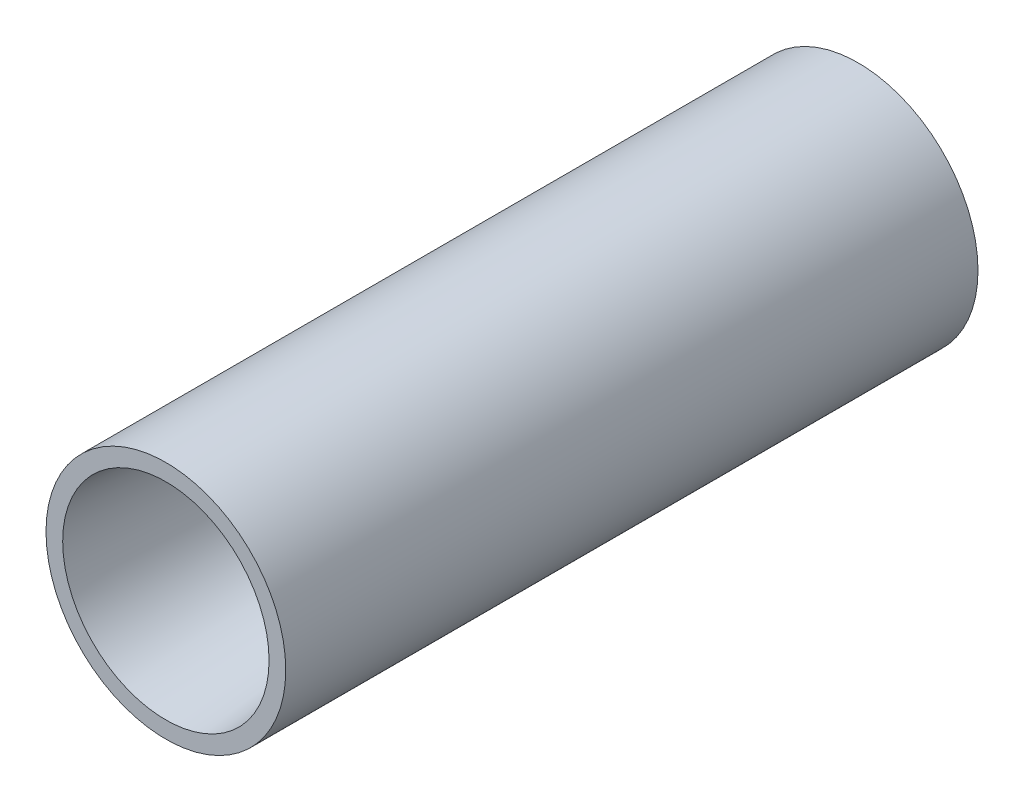
from build123d import *

# Parameters (mm, degrees)
SKETCH1_R           = 12.121929558
BOSS_EXTRUDE1_DEPTH = 70
SKETCH2_R           = 6.435362547
CUT_EXTRUDE1_DEPTH  = 60
CHAMFER1_SIZE       = 4
CHAMFER1_SIZE2      = 45.720209211


with BuildPart() as part:
    # Sketch1 → Boss-Extrude1 (new body)
    with BuildSketch(Plane.XY):
        Circle(SKETCH1_R)
    extrude(amount=BOSS_EXTRUDE1_DEPTH)

    # Sketch2 → Cut-Extrude1 (cut)
    with BuildSketch(Plane.XY.offset(70)):
        Circle(SKETCH2_R)
    extrude(amount=-CUT_EXTRUDE1_DEPTH, mode=Mode.SUBTRACT)

    # Chamfer1
    chamfer1_edges = [part.edges().sort_by_distance(p)[0] for p in [
        (-6.435362547, 0, 70),
    ]]
    chamfer1_side = [part.faces().sort_by_distance(p)[0] for p in [
        (-11.779069614, 0, 70),
    ]]
    chamfer(chamfer1_edges, length=CHAMFER1_SIZE, length2=CHAMFER1_SIZE2, reference=chamfer1_side[0])


solid = part.part
